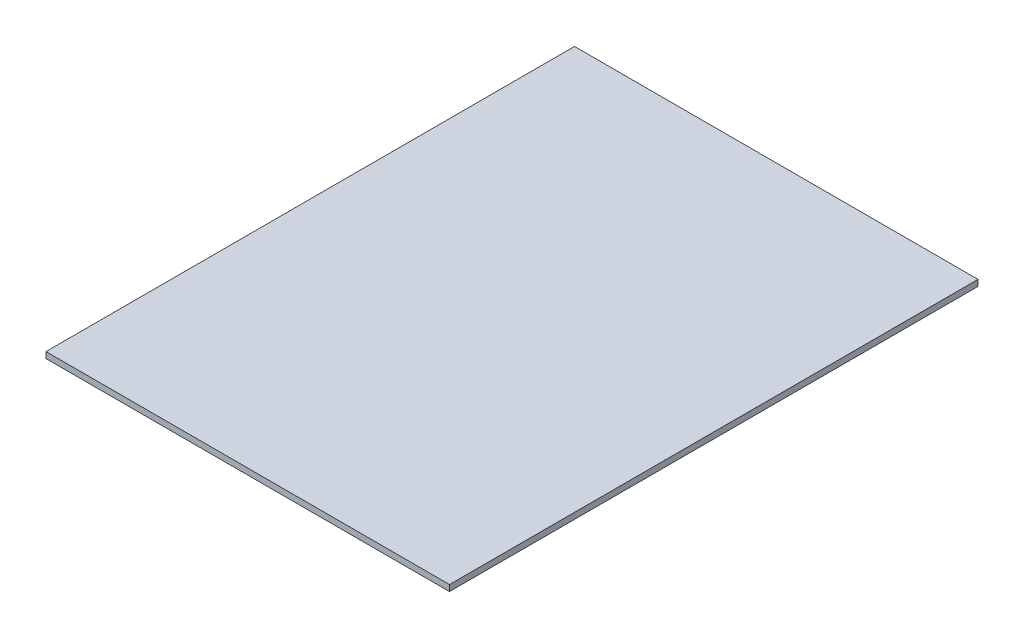
from build123d import *

# Parameters (mm, degrees)
SKETCH1_W           = 397
SKETCH1_H           = 520
BOSS_EXTRUDE1_DEPTH = 6


with BuildPart() as part:
    # Sketch1 → Boss-Extrude1 (new body)
    with BuildSketch(Plane(origin=(0, 0, 0), x_dir=(1, 0, 0), z_dir=(0, 1, 0))):
        Rectangle(SKETCH1_W, SKETCH1_H)
    extrude(amount=BOSS_EXTRUDE1_DEPTH)


solid = part.part
